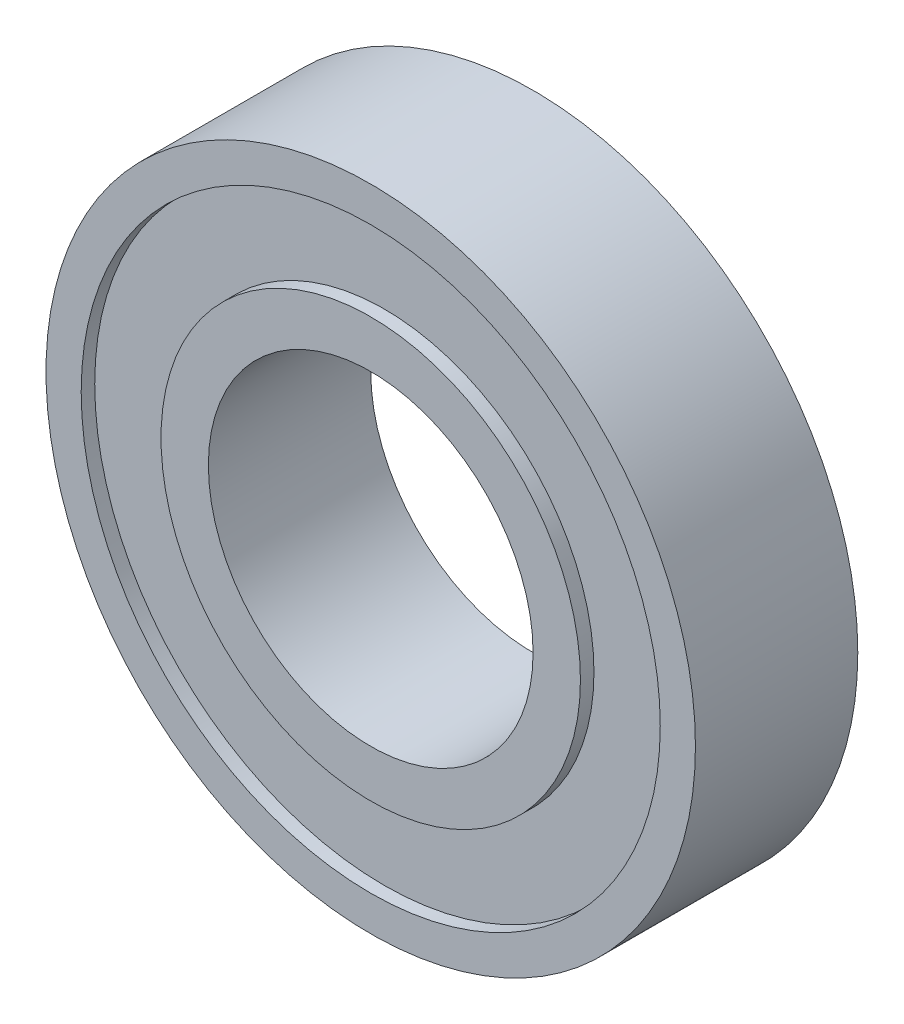
from build123d import *

# Parameters (mm, degrees)
SKETCH_1_R          = 12
EXTRUDE_1_DEPTH     = 3
SKETCH_2_R          = 6
CUT_EXTRUDE_1_DEPTH = 7
SKETCH_3_R          = 10.7
SKETCH_3_R_2        = 7.75
CUT_EXTRUDE_2_DEPTH = 0.5


with BuildPart() as part:
    # 草圖1 → 填料-伸長1 (new body, symmetric)
    with BuildSketch(Plane.XY):
        Circle(SKETCH_1_R)
    extrude(amount=EXTRUDE_1_DEPTH, both=True)

    # 草圖2 → 除料-伸長1 (cut, through all)
    with BuildSketch(Plane.XY.offset(3)):
        Circle(SKETCH_2_R)
    extrude(amount=-CUT_EXTRUDE_1_DEPTH, mode=Mode.SUBTRACT)

    # 草圖3 → 除料-伸長2 (cut)
    with BuildSketch(Plane.XY.offset(3)):
        Circle(SKETCH_3_R)
        Circle(SKETCH_3_R_2, mode=Mode.SUBTRACT)
    cut_extrude_2 = extrude(amount=-CUT_EXTRUDE_2_DEPTH, mode=Mode.SUBTRACT)

    # 鏡射1: 除料-伸長2 across plane
    add(cut_extrude_2.mirror(Plane.XY), mode=Mode.SUBTRACT)


solid = part.part
